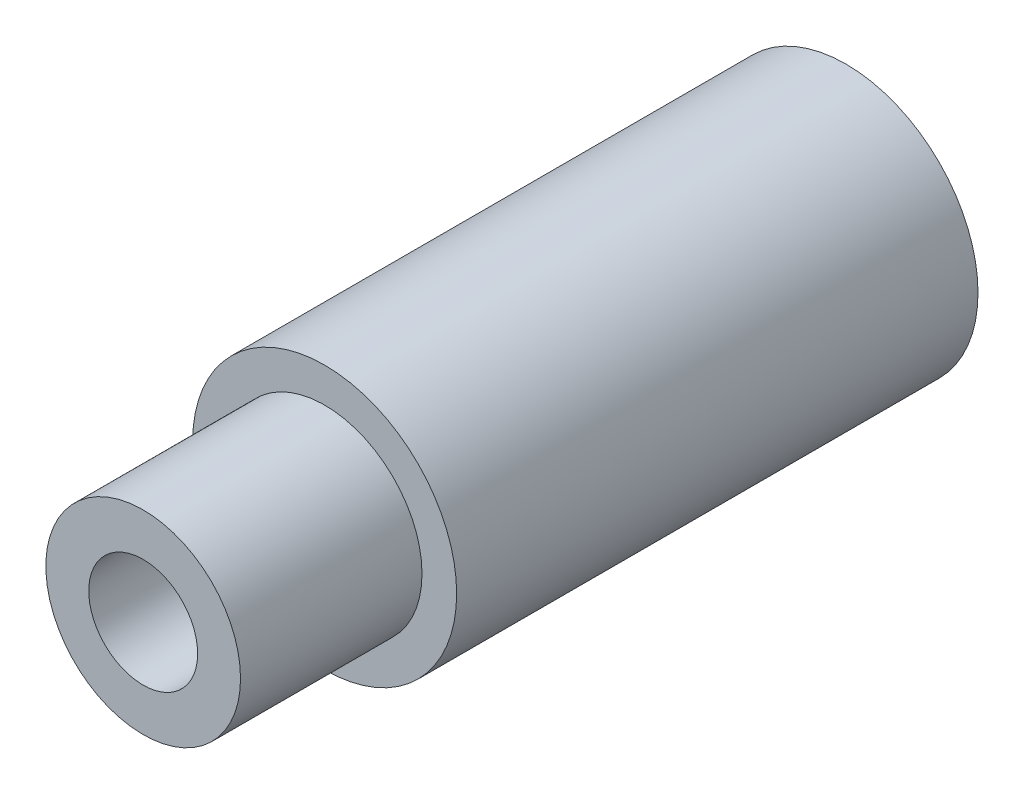
from build123d import *

# Parameters (mm, degrees)
SKETCH_1_R               = 4
EXTRUDE_1_DEPTH          = 7.9
SKETCH_2_R               = 2.95
EXTRUDE_2_DEPTH          = 5.5
M4X0_7_1_D               = 3.3
M4X0_7_1_DEPTH           = 7
M4X0_7_1_TIP             = 0.991420021
M4X0_7_1_ON_FACE_2_D     = 3.3
M4X0_7_1_ON_FACE_2_DEPTH = 7
M4X0_7_1_ON_FACE_2_TIP   = 0.991420021


with BuildPart() as part:
    # ｽｹｯﾁ1 → ﾎﾞｽ - 押し出し1 (new body, symmetric)
    with BuildSketch(Plane.XY):
        Circle(SKETCH_1_R)
    extrude(amount=EXTRUDE_1_DEPTH, both=True)

    # ｽｹｯﾁ2 → ﾎﾞｽ - 押し出し2 (add)
    with BuildSketch(Plane.XY.offset(7.9)):
        Circle(SKETCH_2_R)
    extrude(amount=EXTRUDE_2_DEPTH)

    # M4x0.7 ねじ穴1
    with Locations(Plane(origin=(0, 0, -7.9), x_dir=(-1, 0, 0), z_dir=(0, 0, -1))):
        with Locations((0, 0)):
            Hole(M4X0_7_1_D / 2, depth=M4X0_7_1_DEPTH)
            with Locations((0, 0, -(M4X0_7_1_DEPTH + M4X0_7_1_TIP / 2))):  # 118° drill point
                Cone(0, M4X0_7_1_D / 2, M4X0_7_1_TIP, mode=Mode.SUBTRACT)

    # M4x0.7 ねじ穴1 on face 2
    with Locations(Plane.XY.offset(13.4)):
        with Locations((0, 0)):
            Hole(M4X0_7_1_ON_FACE_2_D / 2, depth=M4X0_7_1_ON_FACE_2_DEPTH)
            with Locations((0, 0, -(M4X0_7_1_ON_FACE_2_DEPTH + M4X0_7_1_ON_FACE_2_TIP / 2))):  # 118° drill point
                Cone(0, M4X0_7_1_ON_FACE_2_D / 2, M4X0_7_1_ON_FACE_2_TIP, mode=Mode.SUBTRACT)


solid = part.part
